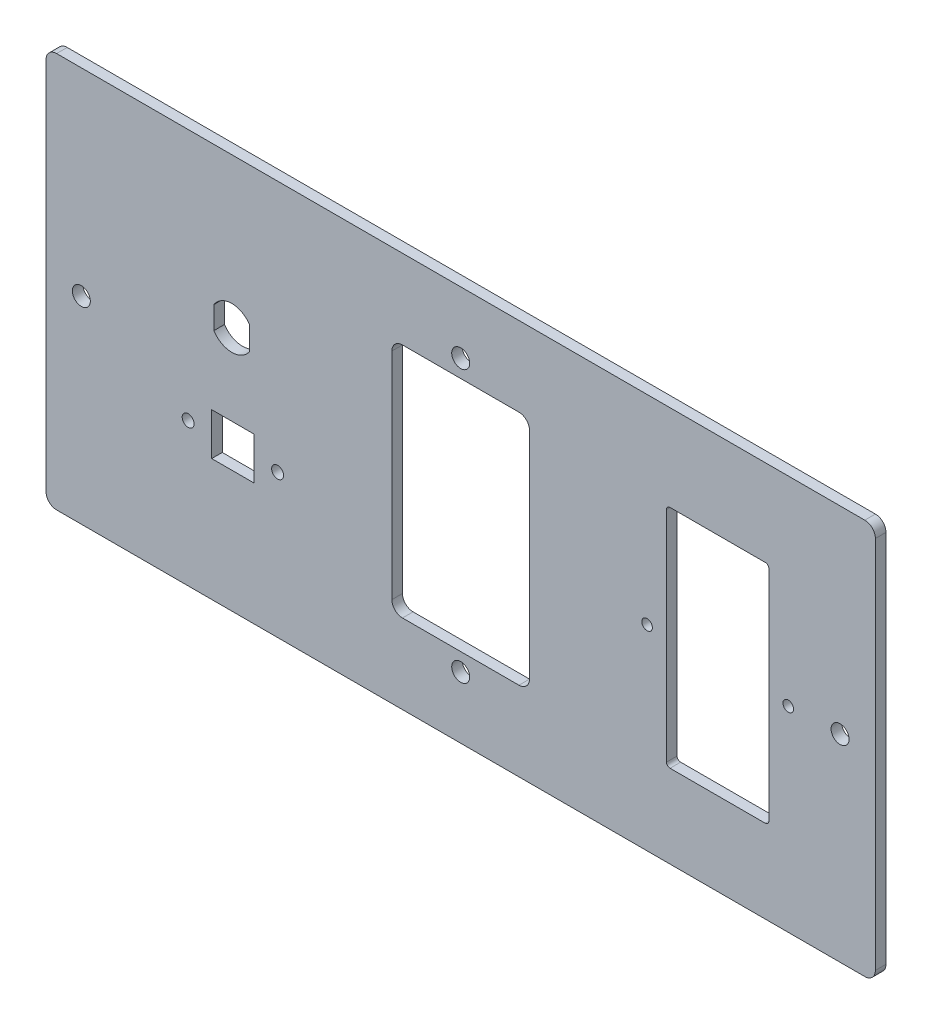
from build123d import *

# Parameters (mm, degrees)
SKETCH1_R           = 2.55
SKETCH1_R_2         = 1.69
SKETCH1_R_3         = 1.5
SKETCH1_W           = 12
SKETCH1_H           = 12
BOSS_EXTRUDE1_DEPTH = 3


with BuildPart() as part:
    # Sketch1 → Boss-Extrude1 (new body)
    with BuildSketch(Plane.XY):
        with BuildLine():
            Line((580.140809409, 26.062600666), (351.140809409, 26.062600666))
            ThreePointArc((351.140809409, 26.062600666), (349.019489066, 25.18392101), (348.140809409, 23.062600666))
            Line((348.140809409, 23.062600666), (348.140809409, -82.937399334))
            ThreePointArc((348.140809409, -82.937399334), (349.019489066, -85.058719677), (351.140809409, -85.937399334))
            Line((351.140809409, -85.937399334), (580.140809409, -85.937399334))
            ThreePointArc((580.140809409, -85.937399334), (582.262129753, -85.058719677), (583.140809409, -82.937399334))
            Line((583.140809409, -82.937399334), (583.140809409, 23.062600666))
            ThreePointArc((583.140809409, 23.062600666), (582.262129753, 25.18392101), (580.140809409, 26.062600666))
        make_face()
        with Locations((465.640809409, 8.562600666)):
            Circle(SKETCH1_R, mode=Mode.SUBTRACT)
        with Locations((465.640809409, -68.437399334)):
            Circle(SKETCH1_R, mode=Mode.SUBTRACT)
        with Locations((388.410230248, -45.355631642)):
            Circle(SKETCH1_R_2, mode=Mode.SUBTRACT)
        with Locations((413.759430248, -45.355631642)):
            Circle(SKETCH1_R_2, mode=Mode.SUBTRACT)
        with Locations((518.453126584, -30.412177954)):
            Circle(SKETCH1_R_3, mode=Mode.SUBTRACT)
        with Locations((558.453126584, -30.412177954)):
            Circle(SKETCH1_R_3, mode=Mode.SUBTRACT)
        with Locations((573.140809409, -29.937399334)):
            Circle(SKETCH1_R, mode=Mode.SUBTRACT)
        with Locations((358.140809409, -29.937399334)):
            Circle(SKETCH1_R, mode=Mode.SUBTRACT)
        with BuildLine():
            Line((405.862321678, -19.639380196), (405.862321678, -13.235418472))
            ThreePointArc((405.862321678, -13.235418472), (400.788140112, -10.437399334), (395.713958547, -13.235418472))
            Line((395.713958547, -13.235418472), (395.713958547, -19.639380196))
            ThreePointArc((395.713958547, -19.639380196), (400.788140112, -22.437399334), (405.862321678, -19.639380196))
        make_face(mode=Mode.SUBTRACT)
        with BuildLine():
            Line((482.140809409, 3.562600666), (449.140809409, 3.562600666))
            ThreePointArc((449.140809409, 3.562600666), (447.019489066, 2.68392101), (446.140809409, 0.562600666))
            Line((446.140809409, 0.562600666), (446.140809409, -60.437399334))
            ThreePointArc((446.140809409, -60.437399334), (447.019489066, -62.558719677), (449.140809409, -63.437399334))
            Line((449.140809409, -63.437399334), (482.140809409, -63.437399334))
            ThreePointArc((482.140809409, -63.437399334), (484.262129753, -62.558719677), (485.140809409, -60.437399334))
            Line((485.140809409, -60.437399334), (485.140809409, 0.562600666))
            ThreePointArc((485.140809409, 0.562600666), (484.262129753, 2.68392101), (482.140809409, 3.562600666))
        make_face(mode=Mode.SUBTRACT)
        with Locations((401.084830248, -45.355631642)):
            Rectangle(SKETCH1_W, SKETCH1_H, mode=Mode.SUBTRACT)
        with BuildLine():
            Line((551.953126584, 1.587822046), (524.953126584, 1.587822046))
            ThreePointArc((524.953126584, 1.587822046), (524.246019803, 1.294928827), (523.953126584, 0.587822046))
            Line((523.953126584, 0.587822046), (523.953126584, -61.412177954))
            ThreePointArc((523.953126584, -61.412177954), (524.246019803, -62.119284735), (524.953126584, -62.412177954))
            Line((524.953126584, -62.412177954), (551.953126584, -62.412177954))
            ThreePointArc((551.953126584, -62.412177954), (552.660233365, -62.119284735), (552.953126584, -61.412177954))
            Line((552.953126584, -61.412177954), (552.953126584, 0.587822046))
            ThreePointArc((552.953126584, 0.587822046), (552.660233365, 1.294928827), (551.953126584, 1.587822046))
        make_face(mode=Mode.SUBTRACT)
    extrude(amount=BOSS_EXTRUDE1_DEPTH)


solid = part.part
